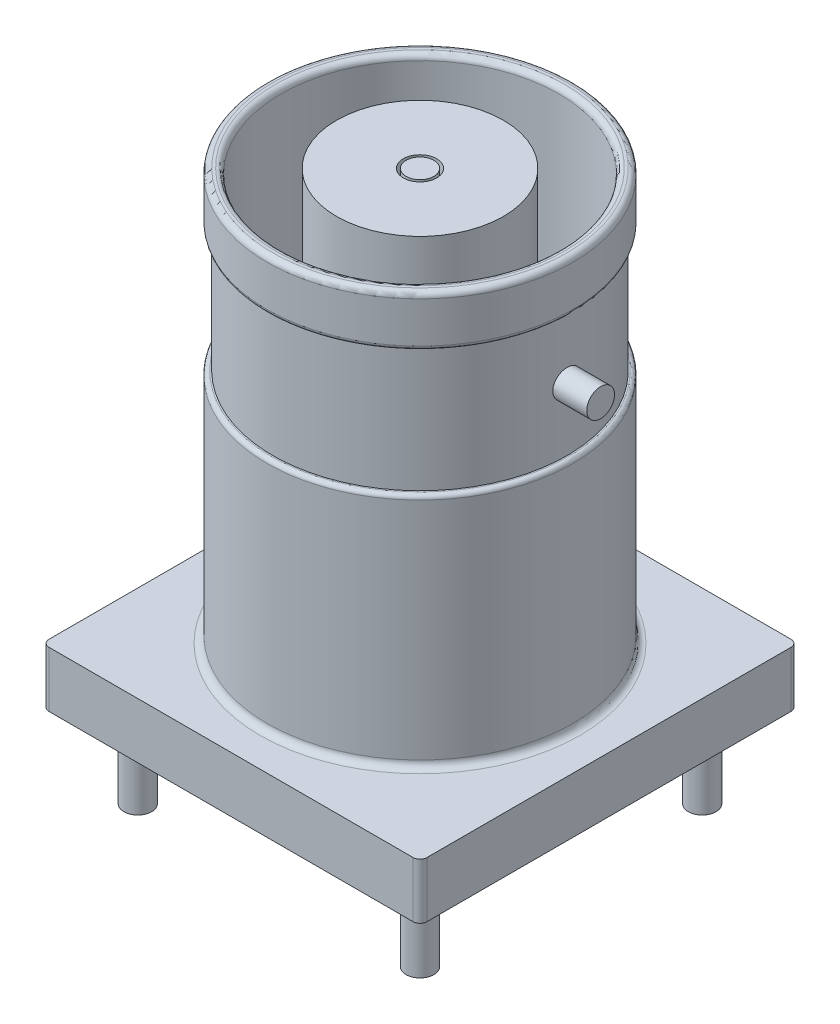
from build123d import *

# Parameters (mm, degrees)
BASE_EXTRUDE_DEPTH  = 2
SKETCH4_R           = 0.5
BOSS_EXTRUDE1_DEPTH = 14.8
SKETCH5_R           = 3
SKETCH5_R_2         = 0.6
BOSS_EXTRUDE2_DEPTH = 14.8
SKETCH6_R           = 0.5
BOSS_EXTRUDE3_DEPTH = 3
SKETCH7_W           = 1.4
SKETCH7_H           = 0.5


with BuildPart() as part:
    # Sketch1 → Base-Extrude (new body)
    with BuildSketch(Plane(origin=(0, 0, 0), x_dir=(1, 0, 0), z_dir=(0, 1, 0))):
        with BuildLine():
            Line((-6.55, -6.8), (6.55, -6.8))
            ThreePointArc((6.55, -6.8), (6.726776695, -6.726776695), (6.8, -6.55))
            Line((6.8, -6.55), (6.8, 6.55))
            ThreePointArc((6.8, 6.55), (6.726776695, 6.726776695), (6.55, 6.8))
            Line((6.55, 6.8), (-6.55, 6.8))
            ThreePointArc((-6.55, 6.8), (-6.726776695, 6.726776695), (-6.8, 6.55))
            Line((-6.8, 6.55), (-6.8, -6.55))
            ThreePointArc((-6.8, -6.55), (-6.726776695, -6.726776695), (-6.55, -6.8))
        make_face()
    extrude(amount=BASE_EXTRUDE_DEPTH)

    # Sketch3 → Boss-Revolve1 (revolve)
    with BuildSketch(Plane(origin=(0, 0, 0), x_dir=(0, 0, -1), z_dir=(1, 0, 0))):
        with BuildLine():
            Line((5.5, 2.25), (5.5, 10.35))
            ThreePointArc((5.5, 10.35), (5.456066017, 10.456066017), (5.35, 10.5))
            Line((5.35, 10.5), (5.3, 10.5))
            Line((5.3, 10.5), (5.3, 15))
            Line((5.3, 15), (5.35, 15))
            ThreePointArc((5.35, 15), (5.456066017, 15.043933983), (5.5, 15.15))
            Line((5.5, 15.15), (5.5, 16.62))
            ThreePointArc((5.5, 16.62), (5.441421356, 16.761421356), (5.3, 16.82))
            Line((5.3, 16.82), (5.2, 16.82))
            ThreePointArc((5.2, 16.82), (5.058578644, 16.761421356), (5, 16.62))
            Line((5, 16.62), (5, 2))
            Line((5, 2), (5.75, 2))
            ThreePointArc((5.75, 2), (5.573223305, 2.073223305), (5.5, 2.25))
        make_face()
    revolve(axis=Axis((0, 0, 0), (0, 1, 0)))

    # Sketch4 → Boss-Extrude1 (add)
    with BuildSketch(Plane(origin=(0, 2, 0), x_dir=(-1, 0, 0), z_dir=(0, 1, 0))):
        Circle(SKETCH4_R)
    extrude(amount=BOSS_EXTRUDE1_DEPTH)

    # Sketch5 → Boss-Extrude2 (add)
    with BuildSketch(Plane(origin=(0, 2, 0), x_dir=(-1, 0, 0), z_dir=(0, 1, 0))):
        Circle(SKETCH5_R)
        Circle(SKETCH5_R_2, mode=Mode.SUBTRACT)
    extrude(amount=BOSS_EXTRUDE2_DEPTH)

    # Sketch6 → Boss-Extrude3 (add)
    with BuildSketch(Plane.XZ):
        Circle(SKETCH6_R)
        with Locations((5.077026689, -5.077026689)):
            Circle(SKETCH6_R)
        with Locations((-5.077026689, -5.077026689)):
            Circle(SKETCH6_R)
        with Locations((5.077026689, 5.077026689)):
            Circle(SKETCH6_R)
        with Locations((-5.077026689, 5.077026689)):
            Circle(SKETCH6_R)
    extrude(amount=BOSS_EXTRUDE3_DEPTH)

    # Sketch7 → Boss-Revolve2 (revolve)
    with BuildSketch(Plane.XY):
        with Locations((5.8, 13)):
            Rectangle(SKETCH7_W, SKETCH7_H)
    boss_revolve2 = revolve(axis=Axis((-7.950895197, 12.75, 0), (1, 0, 0)))

    # Mirror1: Boss-Revolve2 across plane
    add(boss_revolve2.mirror(Plane(origin=(0, 0, 0), x_dir=(0, 0, 1), z_dir=(1, 0, 0))))


solid = part.part
